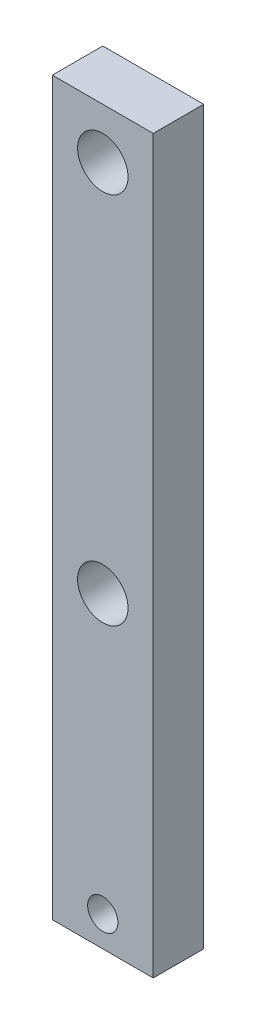
from build123d import *

# Parameters (mm, degrees)
SKETCH1_W           = 10
SKETCH1_H           = 72.5
BOSS_EXTRUDE1_DEPTH = 5
SKETCH2_R           = 2.5
CUT_EXTRUDE1_DEPTH  = 6
SKETCH3_R           = 1.5
SKETCH3_R_2         = 2.5
CUT_EXTRUDE2_DEPTH  = 6


with BuildPart() as part:
    # Sketch1 → Boss-Extrude1 (new body)
    with BuildSketch(Plane.XY):
        with Locations((-5, 36.25)):
            Rectangle(SKETCH1_W, SKETCH1_H)
    extrude(amount=BOSS_EXTRUDE1_DEPTH)

    # Sketch2 → Cut-Extrude1 (cut, through all)
    with BuildSketch(Plane.XY.offset(5)):
        with Locations((-5, 67.5)):
            Circle(SKETCH2_R)
    extrude(amount=-CUT_EXTRUDE1_DEPTH, mode=Mode.SUBTRACT)

    # Sketch3 → Cut-Extrude2 (cut, through all)
    with BuildSketch(Plane.XY.offset(5)):
        with Locations((-5, 3)):
            Circle(SKETCH3_R)
        with Locations((-5, 30.5)):
            Circle(SKETCH3_R_2)
    extrude(amount=-CUT_EXTRUDE2_DEPTH, mode=Mode.SUBTRACT)


solid = part.part
